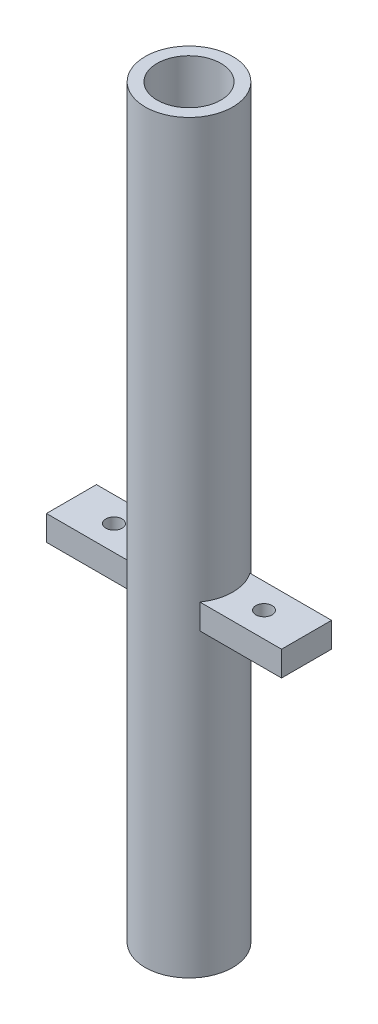
from build123d import *

# Parameters (mm, degrees)
SKETCH1_R           = 17.5
SKETCH1_R_2         = 12.75
BOSS_EXTRUDE1_DEPTH = 149
SKETCH3_R           = 3.25
BOSS_EXTRUDE2_DEPTH = 10


with BuildPart() as part:
    # Sketch1 → Boss-Extrude1 (new body, symmetric)
    with BuildSketch(Plane(origin=(0, 0, 0), x_dir=(1, 0, 0), z_dir=(0, 1, 0))):
        Circle(SKETCH1_R)
        Circle(SKETCH1_R_2, mode=Mode.SUBTRACT)
    extrude(amount=BOSS_EXTRUDE1_DEPTH, both=True)

    # Sketch3 → Boss-Extrude2 (add)
    with BuildSketch(Plane(origin=(0, -29, 0), x_dir=(-1, 0, 0), z_dir=(0, -1, 0))):
        with BuildLine():
            Line((47, -10), (7.90964601, -10))
            ThreePointArc((7.90964601, -10), (12.75, 0), (7.90964601, 10))
            Line((7.90964601, 10), (47, 10))
            Line((47, 10), (47, -10))
        make_face()
        with Locations((30, 0)):
            Circle(SKETCH3_R, mode=Mode.SUBTRACT)
        with BuildLine():
            Line((-47, -10), (-47, 10))
            Line((-47, 10), (-7.90964601, 10))
            ThreePointArc((-7.90964601, 10), (-12.75, 0), (-7.90964601, -10))
            Line((-7.90964601, -10), (-47, -10))
        make_face()
        with Locations((-30, 0)):
            Circle(SKETCH3_R, mode=Mode.SUBTRACT)
    extrude(amount=-BOSS_EXTRUDE2_DEPTH)


solid = part.part
